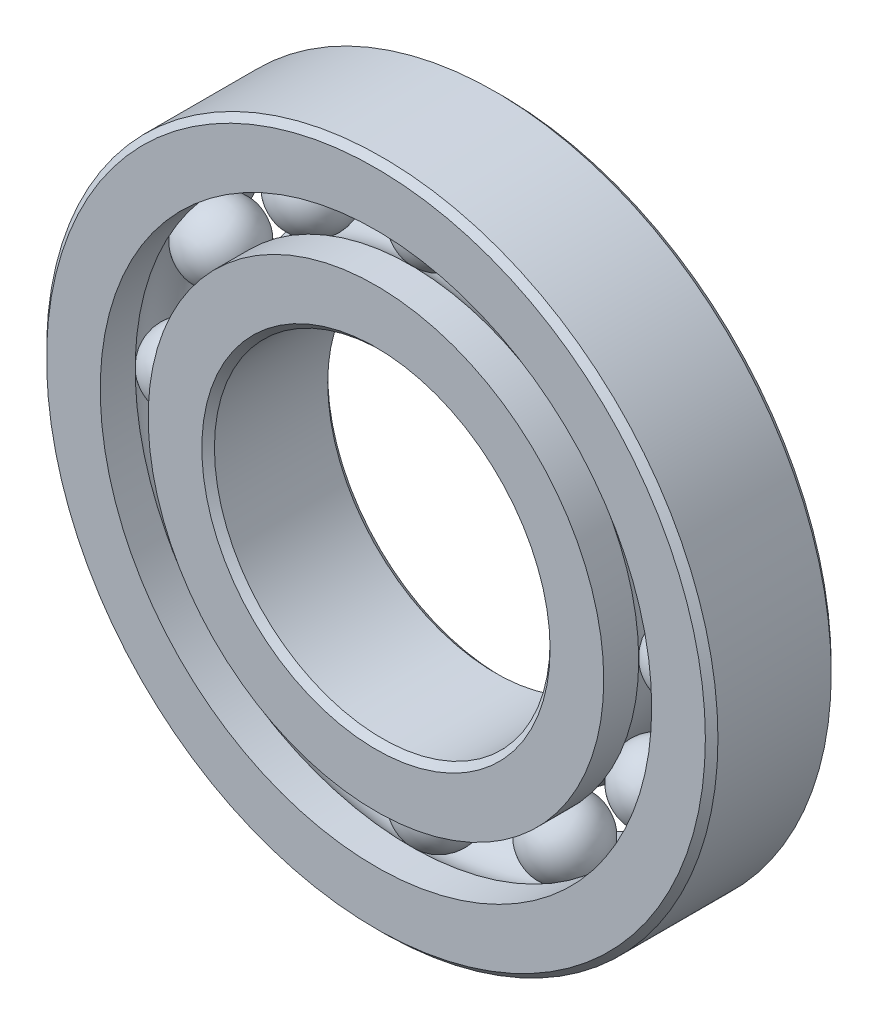
from build123d import *

# Parameters (mm, degrees)
CIRPATTERN1_COUNT = 12


with BuildPart() as part:
    # Sketch1 → Revolve1 (revolve)
    with BuildSketch(Plane(origin=(0, 0, 0), x_dir=(0, 0, -1), z_dir=(1, 0, 0))):
        with BuildLine():
            Line((4.28625, 25.4), (-4.28625, 25.4))
            Line((-4.28625, 25.4), (-4.7625, 24.92375))
            Line((-4.7625, 24.92375), (-4.7625, 20.864285714))
            Line((-4.7625, 20.864285714), (-2.116666667, 20.864285714))
            ThreePointArc((-2.116666667, 20.864285714), (0, 21.837814634), (2.116666667, 20.864285714))
            Line((2.116666667, 20.864285714), (4.7625, 20.864285714))
            Line((4.7625, 20.864285714), (4.7625, 24.92375))
            Line((4.7625, 24.92375), (4.28625, 25.4))
        make_face()
    revolve(axis=Axis((0, 0, 4.7625), (0, 0, -1)))


with BuildPart() as body_2:
    # Sketch3 → Revolve3 (revolve)
    with BuildSketch(Plane(origin=(0, 0, 0), x_dir=(0, 0, -1), z_dir=(1, 0, 0))):
        with BuildLine():
            Line((-4.7625, 17.235714286), (-2.116666667, 17.235714286))
            ThreePointArc((-2.116666667, 17.235714286), (0, 16.262185366), (2.116666667, 17.235714286))
            Line((2.116666667, 17.235714286), (4.7625, 17.235714286))
            Line((4.7625, 17.235714286), (4.7625, 13.17625))
            Line((4.7625, 13.17625), (4.28625, 12.7))
            Line((4.28625, 12.7), (-4.28625, 12.7))
            Line((-4.28625, 12.7), (-4.7625, 13.17625))
            Line((-4.7625, 13.17625), (-4.7625, 17.235714286))
        make_face()
    revolve(axis=Axis((0, 0, 4.7625), (0, 0, -1)))


with BuildPart() as body_3:
    # Sketch4 → Revolve4 (revolve)
    with BuildSketch(Plane(origin=(0, 0, 0), x_dir=(0, 0, -1), z_dir=(1, 0, 0))):
        with BuildLine():
            Line((-2.787814634, 19.05), (2.787814634, 19.05))
            ThreePointArc((2.787814634, 19.05), (0, 21.837814634), (-2.787814634, 19.05))
        make_face()
    revolve(axis=Axis((0, 19.05, 2.787814634), (0, 0, -1)))


with BuildPart() as cirpattern1_1:
    # CirPattern1: pattern copy
    add(body_3.part.rotate(Axis((0, 0, -4.7625), (0, 0, 1)), 1 * 360 / CIRPATTERN1_COUNT))


with BuildPart() as cirpattern1_2:
    # CirPattern1: pattern copy
    add(body_3.part.rotate(Axis((0, 0, -4.7625), (0, 0, 1)), 2 * 360 / CIRPATTERN1_COUNT))


with BuildPart() as cirpattern1_3:
    # CirPattern1: pattern copy
    add(body_3.part.rotate(Axis((0, 0, -4.7625), (0, 0, 1)), 3 * 360 / CIRPATTERN1_COUNT))


with BuildPart() as cirpattern1_4:
    # CirPattern1: pattern copy
    add(body_3.part.rotate(Axis((0, 0, -4.7625), (0, 0, 1)), 4 * 360 / CIRPATTERN1_COUNT))


with BuildPart() as cirpattern1_5:
    # CirPattern1: pattern copy
    add(body_3.part.rotate(Axis((0, 0, -4.7625), (0, 0, 1)), 5 * 360 / CIRPATTERN1_COUNT))


with BuildPart() as cirpattern1_6:
    # CirPattern1: pattern copy
    add(body_3.part.rotate(Axis((0, 0, -4.7625), (0, 0, 1)), 6 * 360 / CIRPATTERN1_COUNT))


with BuildPart() as cirpattern1_7:
    # CirPattern1: pattern copy
    add(body_3.part.rotate(Axis((0, 0, -4.7625), (0, 0, 1)), 7 * 360 / CIRPATTERN1_COUNT))


with BuildPart() as cirpattern1_8:
    # CirPattern1: pattern copy
    add(body_3.part.rotate(Axis((0, 0, -4.7625), (0, 0, 1)), 8 * 360 / CIRPATTERN1_COUNT))


with BuildPart() as cirpattern1_9:
    # CirPattern1: pattern copy
    add(body_3.part.rotate(Axis((0, 0, -4.7625), (0, 0, 1)), 9 * 360 / CIRPATTERN1_COUNT))


with BuildPart() as cirpattern1_10:
    # CirPattern1: pattern copy
    add(body_3.part.rotate(Axis((0, 0, -4.7625), (0, 0, 1)), 10 * 360 / CIRPATTERN1_COUNT))


with BuildPart() as cirpattern1_11:
    # CirPattern1: pattern copy
    add(body_3.part.rotate(Axis((0, 0, -4.7625), (0, 0, 1)), 11 * 360 / CIRPATTERN1_COUNT))


solid = Compound([part.part, body_2.part, body_3.part, cirpattern1_1.part, cirpattern1_2.part, cirpattern1_3.part, cirpattern1_4.part, cirpattern1_5.part, cirpattern1_6.part, cirpattern1_7.part, cirpattern1_8.part, cirpattern1_9.part, cirpattern1_10.part, cirpattern1_11.part])
